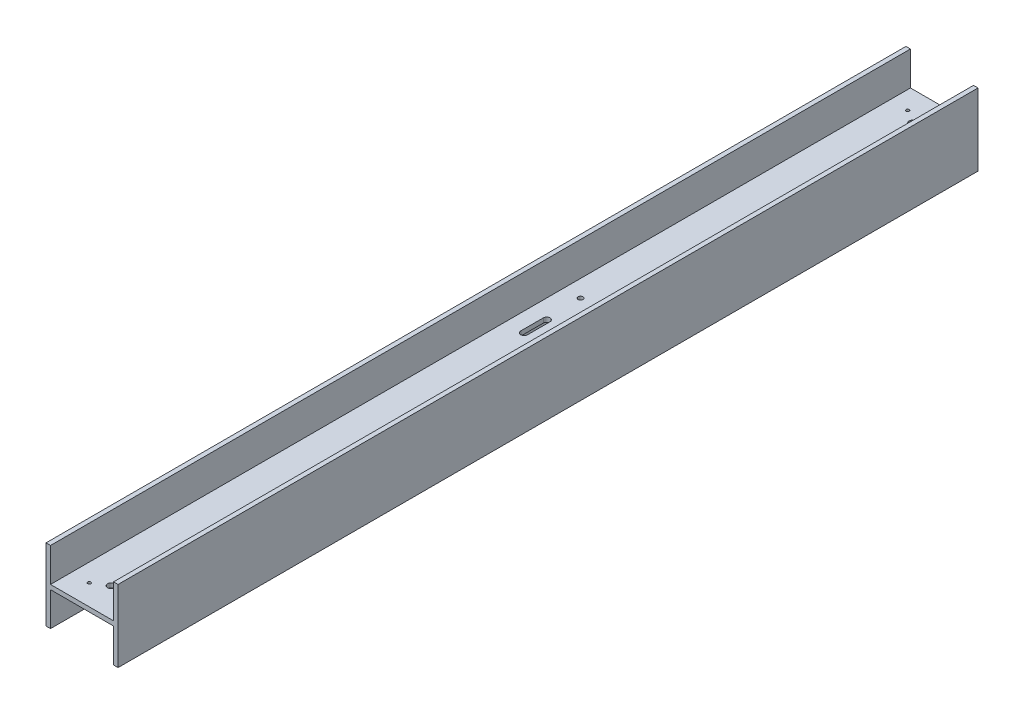
from build123d import *

# Parameters (mm, degrees)
EXTRUSION_PROFILE_DEPTH                      = 303.2125
SKETCH3_R                                    = 1.7272
THRU_HOLES_FOR_DRIVER_ENCLOSURE_DEPTH        = 306.468992391
WIRE_ROUTING_SLOT_DEPTH                      = 306.468992391
SKETCH5_R                                    = 1.0922
F_4_40_TAPPED_HOLES_FOR_MAGNETIC_CATCH_DEPTH = 306.468992391
F_1_4_20_TAPPED_HOLE_FOR_MOUNTING_BRACKET_D  = 5.1054
SKETCH9_R                                    = 1.0922
F_4_40_TAPPED_HOLES_FOR_LED_BOARD_DEPTH      = 306.468992391


with BuildPart() as part:
    # Sketch1 → Extrusion Profile (new, symmetric)
    with BuildSketch(Plane.XY):
        Polygon((-25.4, -25.4), (-25.4, 25.4), (-22.225, 25.4), (-22.225, 1.5875), (22.225, 1.5875), (22.225, 25.4), (25.4, 25.4), (25.4, -25.4), (22.225, -25.4), (22.225, -1.5875), (-22.225, -1.5875), (-22.225, -25.4), align=None)
    extrude(amount=EXTRUSION_PROFILE_DEPTH, both=True)

    # Sketch3 → Thru Holes for Driver Enclosure (cut, through all)
    with BuildSketch(Plane(origin=(0, 1.5875, 0), x_dir=(1, 0, 0), z_dir=(0, 1, 0))):
        with Locations((10.16, -58.547)):
            Circle(SKETCH3_R)
        with Locations((-10.16, 58.547)):
            Circle(SKETCH3_R)
    extrude(amount=-THRU_HOLES_FOR_DRIVER_ENCLOSURE_DEPTH, mode=Mode.SUBTRACT)

    # Sketch4 → Wire Routing Slot (cut, through all)
    with BuildSketch(Plane.XZ.offset(1.5875)):
        with BuildLine():
            Line((-11.27125, -33.3375), (-11.27125, -17.4625))
            ThreePointArc((-11.27125, -17.4625), (-8.89, -15.08125), (-6.50875, -17.4625))
            Line((-6.50875, -17.4625), (-6.50875, -33.3375))
            ThreePointArc((-6.50875, -33.3375), (-8.89, -35.71875), (-11.27125, -33.3375))
        make_face()
    extrude(amount=-WIRE_ROUTING_SLOT_DEPTH, mode=Mode.SUBTRACT)

    # Sketch5 → 4-40 Tapped Holes for Magnetic Catch (cut, through all)
    with BuildSketch(Plane(origin=(0, 1.5875, 0), x_dir=(1, 0, 0), z_dir=(0, 1, 0))):
        with Locations((-9.525, -288.544)):
            Circle(SKETCH5_R)
        with Locations((9.525, -288.544)):
            Circle(SKETCH5_R)
        with Locations((9.525, 288.544)):
            Circle(SKETCH5_R)
        with Locations((-9.525, 288.544)):
            Circle(SKETCH5_R)
    extrude(amount=-F_4_40_TAPPED_HOLES_FOR_MAGNETIC_CATCH_DEPTH, mode=Mode.SUBTRACT)

    # 1_4-20 Tapped Hole for Mounting Bracket (through all)
    with Locations(Plane(origin=(0, 1.5875, 0), x_dir=(1, 0, 0), z_dir=(0, 1, 0))):
        with Locations((0, -282.575)):
            f_1_4_20_tapped_hole_for_mounting_bracket = Hole(F_1_4_20_TAPPED_HOLE_FOR_MOUNTING_BRACKET_D / 2)

    # Mirror1: 1_4-20 Tapped Hole for Mounting Bracket across plane
    add(f_1_4_20_tapped_hole_for_mounting_bracket.mirror(Plane.XY), mode=Mode.SUBTRACT)

    # Sketch9 → 4-40 Tapped Holes for LED Board (cut, through all)
    with BuildSketch(Plane.XZ.offset(1.5875)):
        with Locations((0, -228.6)):
            Circle(SKETCH9_R)
        with Locations((0, -146.05)):
            Circle(SKETCH9_R)
        with Locations((0, 146.05)):
            Circle(SKETCH9_R)
        with Locations((0, 228.6)):
            Circle(SKETCH9_R)
    extrude(amount=-F_4_40_TAPPED_HOLES_FOR_LED_BOARD_DEPTH, mode=Mode.SUBTRACT)


solid = part.part
